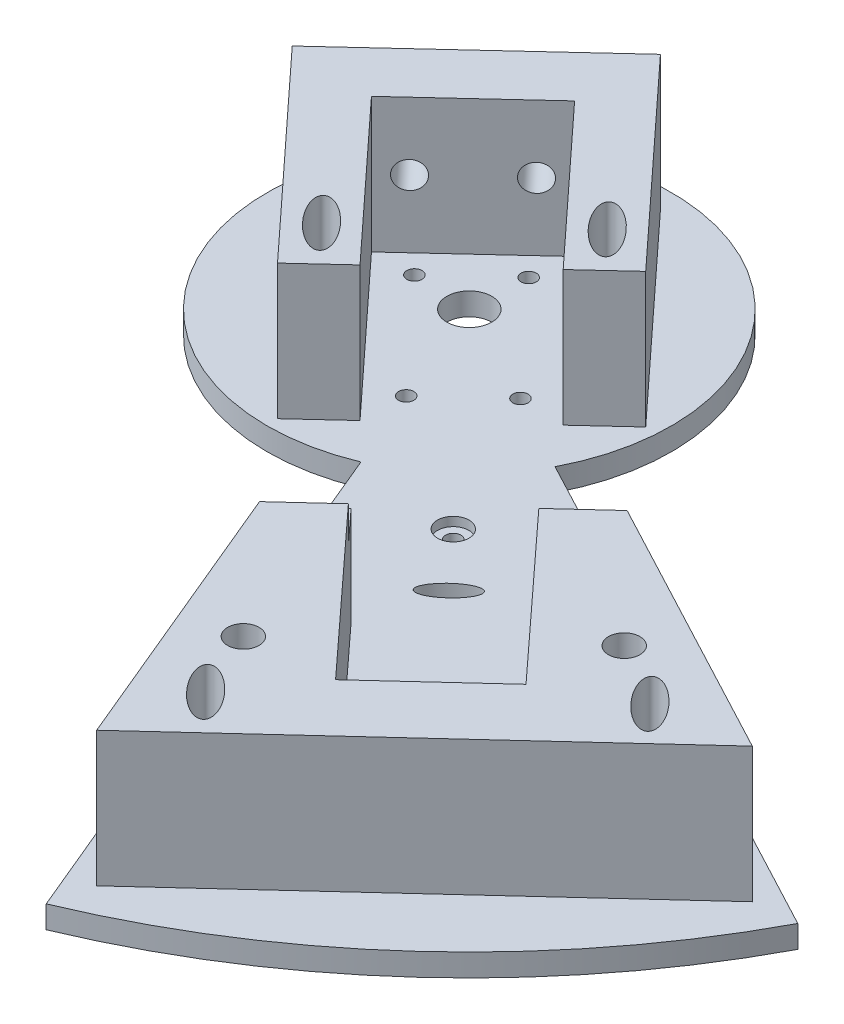
from build123d import *

# Parameters (mm, degrees)
EXTRUDE_1_DEPTH          = 5
SKETCH_1_5_R             = 5
SKETCH_1_5_R_2           = 1.7
CUT_EXTRUDE_2_DEPTH      = 5
EXTRUDE_2_DEPTH          = 30
EXTRUDE_3_DEPTH          = 30
SKETCH_4_R               = 1.7
CUT_EXTRUDE_3_DEPTH      = 30
CUT_EXTRUDE_3_DEPTH_BACK = 30
SKETCH_5_RX              = 7.5
SKETCH_5_RY              = 3
CUT_EXTRUDE_4_DEPTH      = 36
SKETCH_7_R               = 3
CUT_EXTRUDE_5_DEPTH      = 9
SKETCH_8_R               = 1.5
CUT_EXTRUDE_6_DEPTH      = 5
SKETCH_10_R              = 1.5
CUT_EXTRUDE_7_DEPTH      = 5
SKETCH_12_R              = 3
CUT_EXTRUDE_9_DEPTH      = 2
SKETCH_13_R              = 3.5
CUT_EXTRUDE_10_DEPTH     = 2
SKETCH_14_R              = 3.5
CUT_EXTRUDE_11_DEPTH     = 30
SKETCH_15_RX             = 5.612274766
SKETCH_15_RY             = 2
CUT_EXTRUDE_12_DEPTH     = 10
CUT_EXTRUDE_13_DEPTH     = 30
CUT_EXTRUDE_14_DEPTH     = 8
SKETCH_18_R              = 1.5
CUT_EXTRUDE_15_DEPTH     = 8


with BuildPart() as part:
    # Sketch 1 → Extrude 1 (new body)
    with BuildSketch(Plane(origin=(0, 0, 0), x_dir=(1, 0, 0), z_dir=(0, 1, 0))):
        with BuildLine():
            Line((67.540595068, -161.712184197), (17.384562367, -41.506348807))
            ThreePointArc((17.384562367, -41.506348807), (-30.453957867, 33.129389524), (39.899218903, -20.80990944))
            Line((39.899218903, -20.80990944), (154.963074519, -81.847468108))
            ThreePointArc((154.963074519, -81.847468108), (118.201370398, -129.387010693), (67.540595068, -161.712184197))
        make_face()
    extrude(amount=EXTRUDE_1_DEPTH)

    # Sketch 1_5 → Cut-Extrude 2 (cut)
    with BuildSketch(Plane(origin=(0, 0, 0), x_dir=(1, 0, 0), z_dir=(0, 1, 0))):
        Circle(SKETCH_1_5_R)
        with Locations((-12.718168021, 0.498198949)):
            Circle(SKETCH_1_5_R_2)
        with Locations((0.498198949, 12.718168021)):
            Circle(SKETCH_1_5_R_2)
        with Locations((9.685108612, -23.731807162)):
            Circle(SKETCH_1_5_R_2)
        with Locations((22.901475581, -11.51183809)):
            Circle(SKETCH_1_5_R_2)
    extrude(amount=CUT_EXTRUDE_2_DEPTH, mode=Mode.SUBTRACT)

    # Sketch 2 → Extrude 2 (add)
    with BuildSketch(Plane(origin=(0, 5, 0), x_dir=(1, 0, 0), z_dir=(0, 1, 0))):
        Polygon((2.136468866, 40.40665523), (8.349325281, 33.687211848), (42.338718823, -3.073625718), (35.730354479, -9.183777478), (32.793384042, -11.899326161), (1.56457419, 21.875833872), (-21.931189311, 0.15144441), (9.297620541, -33.623715623), (6.360650103, -36.339264306), (-0.244095394, -42.446070048), (-34.188453929, -5.733939577), (-40.446345352, 1.0342109), align=None)
    extrude(amount=EXTRUDE_2_DEPTH)

    # Sketch 3 → Extrude 3 (add)
    with BuildSketch(Plane(origin=(0, 5, 0), x_dir=(1, 0, 0), z_dir=(0, 1, 0))):
        Polygon((39.640129458, -80.617349847), (77.002361645, -46.272381189), (145.720646242, -82.725151742), (69.683904227, -152.621391033), align=None)
    extrude(amount=EXTRUDE_3_DEPTH)

    # Sketch 4 → Cut-Extrude 3 (cut, two sides)
    with BuildSketch(Plane(origin=(0, 5, 0), x_dir=(1, 0, 0), z_dir=(0, 1, 0))) as cut_extrude_3_sk:
        with Locations((40.605277156, -44.172519365)):
            Circle(SKETCH_4_R)
        with Locations((67.922104681, -118.218389837)):
            Circle(SKETCH_4_R)
        with Locations((112.094624046, -77.613112681)):
            Circle(SKETCH_4_R)
    extrude(amount=CUT_EXTRUDE_3_DEPTH, mode=Mode.SUBTRACT)
    extrude(cut_extrude_3_sk.sketch, amount=-CUT_EXTRUDE_3_DEPTH_BACK, mode=Mode.SUBTRACT)

    # Sketch 5 → Cut-Extrude 4 (cut, through all)
    with BuildSketch(Plane(origin=(0, 35, 0), x_dir=(1, 0, 0), z_dir=(0, 1, 0))):
        with Locations(Location((74.41780144, -133.105180027), (0, 0, 132.321365352))):
            Ellipse(SKETCH_5_RX, SKETCH_5_RY)
        with Locations(Location((126.174407045, -85.975000987), (0, 0, 132.321365352))):
            Ellipse(SKETCH_5_RX, SKETCH_5_RY)
        with Locations(Location((-3.088812762, -29.798173528), (0, 0, -47.243256279))):
            Ellipse(SKETCH_5_RX, SKETCH_5_RY)
        with Locations(Location((29.952104662, 0.751749153), (0, 0, -47.243256279))):
            Ellipse(SKETCH_5_RX, SKETCH_5_RY)
    extrude(amount=-CUT_EXTRUDE_4_DEPTH, mode=Mode.SUBTRACT)

    # Sketch 7 → Cut-Extrude 5 (cut)
    with BuildSketch(Plane(origin=(-10.18330756, 0, -11.013639141), x_dir=(0.734242609, 0, -0.678887171), z_dir=(0.678887171, 0, 0.734242609))):
        with Locations((-10, 20)):
            Circle(SKETCH_7_R)
        with Locations((10, 20)):
            Circle(SKETCH_7_R)
    extrude(amount=-CUT_EXTRUDE_5_DEPTH, mode=Mode.SUBTRACT)

    # Sketch 8 → Cut-Extrude 6 (cut)
    with BuildSketch(Plane(origin=(-19.156747666, 0, -20.718760056), x_dir=(-0.734242609, 0, 0.678887171), z_dir=(-0.678887171, 0, -0.734242609))):
        with Locations((-10, 20)):
            Circle(SKETCH_8_R)
        with Locations((10, 20)):
            Circle(SKETCH_8_R)
    extrude(amount=-CUT_EXTRUDE_6_DEPTH, mode=Mode.SUBTRACT)

    # Sketch 10 → Cut-Extrude 7 (cut)
    with BuildSketch(Plane(origin=(0, 5, 0), x_dir=(1, 0, 0), z_dir=(0, 1, 0))):
        with Locations((-17.650139673, 33.977138764)):
            Circle(SKETCH_10_R)
        with Locations((-32.374312795, 20.442046379)):
            Circle(SKETCH_10_R)
    extrude(amount=-CUT_EXTRUDE_7_DEPTH, mode=Mode.SUBTRACT)

    # Sketch 12 → Cut-Extrude 9 (cut)
    with BuildSketch(Plane.XZ):
        with Locations((-12.718168021, -0.498198949)):
            Circle(SKETCH_12_R)
        with Locations((9.685108612, 23.731807162)):
            Circle(SKETCH_12_R)
        with Locations((22.901475581, 11.51183809)):
            Circle(SKETCH_12_R)
        with Locations((0.498198949, -12.718168021)):
            Circle(SKETCH_12_R)
    extrude(amount=-CUT_EXTRUDE_9_DEPTH, mode=Mode.SUBTRACT)

    # Sketch 13 → Cut-Extrude 10 (cut)
    with BuildSketch(Plane(origin=(0, 5, 0), x_dir=(1, 0, 0), z_dir=(0, 1, 0))):
        with Locations((40.605277156, -44.172519365)):
            Circle(SKETCH_13_R)
    extrude(amount=-CUT_EXTRUDE_10_DEPTH, mode=Mode.SUBTRACT)

    # Sketch 14 → Cut-Extrude 11 (cut)
    with BuildSketch(Plane(origin=(0, 35, 0), x_dir=(1, 0, 0), z_dir=(0, 1, 0))):
        with Locations((67.922104681, -118.218389837)):
            Circle(SKETCH_14_R)
        with Locations((112.094624046, -77.613112681)):
            Circle(SKETCH_14_R)
    extrude(amount=-CUT_EXTRUDE_11_DEPTH, mode=Mode.SUBTRACT)

    # Sketch 15 → Cut-Extrude 12 (cut)
    with BuildSketch(Plane(origin=(0, 5, 0), x_dir=(1, 0, 0), z_dir=(0, 1, 0))):
        with Locations(Location((51.956370637, -56.520825588), (0, 0, -137.409444867))):
            Ellipse(SKETCH_15_RX, SKETCH_15_RY)
    extrude(amount=-CUT_EXTRUDE_12_DEPTH, mode=Mode.SUBTRACT)

    # Sketch 16 → Cut-Extrude 13 (cut)
    with BuildSketch(Plane(origin=(0, 35, 0), x_dir=(1, 0, 0), z_dir=(0, 1, 0))):
        Polygon((47.27811571, -73.596184807), (69.364375393, -53.293546229), (103.202106357, -90.103979033), (81.115846674, -110.406617612), align=None)
    extrude(amount=-CUT_EXTRUDE_13_DEPTH, mode=Mode.SUBTRACT)

    # Sketch 17 → Cut-Extrude 14 (cut)
    with BuildSketch(Plane(origin=(0, 35, 0), x_dir=(1, 0, 0), z_dir=(0, 1, 0))):
        Polygon((47.27811571, -73.596184807), (39.640129458, -80.617349847), (43.736509097, -90.43488744), (54.045661903, -80.958271368), align=None)
        Polygon((69.364375393, -53.293546229), (77.002361645, -46.272381189), (86.441074392, -51.179016718), (76.131921586, -60.65563279), align=None)
        Polygon((81.115846674, -110.406617612), (103.202106357, -90.103979033), (108.616143311, -95.993648282), (86.529883628, -116.29628686), align=None)
    extrude(amount=-CUT_EXTRUDE_14_DEPTH, mode=Mode.SUBTRACT)

    # Sketch 18 → Cut-Extrude 15 (cut)
    with BuildSketch(Plane(origin=(0, 27, 0), x_dir=(1, 0, 0), z_dir=(0, 1, 0))):
        with Locations((46.842895681, -80.787810608)):
            Circle(SKETCH_18_R)
        with Locations((76.567141615, -53.46400699)):
            Circle(SKETCH_18_R)
        with Locations((94.865994992, -103.200132947)):
            Circle(SKETCH_18_R)
    extrude(amount=-CUT_EXTRUDE_15_DEPTH, mode=Mode.SUBTRACT)


solid = part.part
